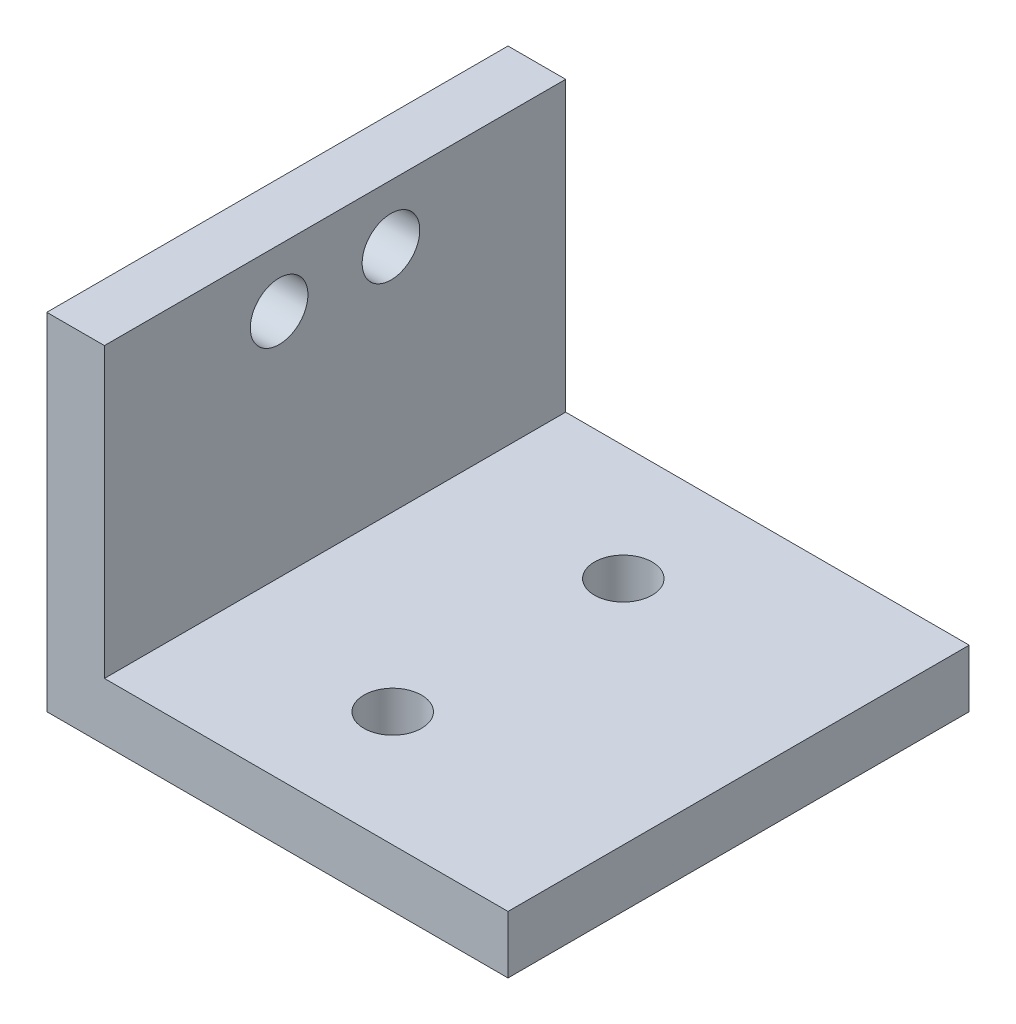
from build123d import *

# Parameters (mm, degrees)
BOSS_EXTRUDE1_DEPTH = 40
SKETCH2_R           = 2.5
CUT_EXTRUDE1_DEPTH  = 40
SKETCH3_R           = 2.5
CUT_EXTRUDE2_DEPTH  = 40


with BuildPart() as part:
    # Sketch1 → Boss-Extrude1 (new body)
    with BuildSketch(Plane.XY):
        Polygon((0, 0), (0, 30), (5, 30), (5, 5), (40, 5), (40, 0), align=None)
    extrude(amount=BOSS_EXTRUDE1_DEPTH)

    # Sketch2 → Cut-Extrude1 (cut)
    with BuildSketch(Plane.ZY):
        with Locations((24.85, 25)):
            Circle(SKETCH2_R)
        with Locations((15.15, 25)):
            Circle(SKETCH2_R)
    extrude(amount=-CUT_EXTRUDE1_DEPTH, mode=Mode.SUBTRACT)

    # Sketch3 → Cut-Extrude2 (cut)
    with BuildSketch(Plane.XZ):
        with Locations((20, 30)):
            Circle(SKETCH3_R)
        with Locations((20, 10)):
            Circle(SKETCH3_R)
    extrude(amount=-CUT_EXTRUDE2_DEPTH, mode=Mode.SUBTRACT)


solid = part.part
